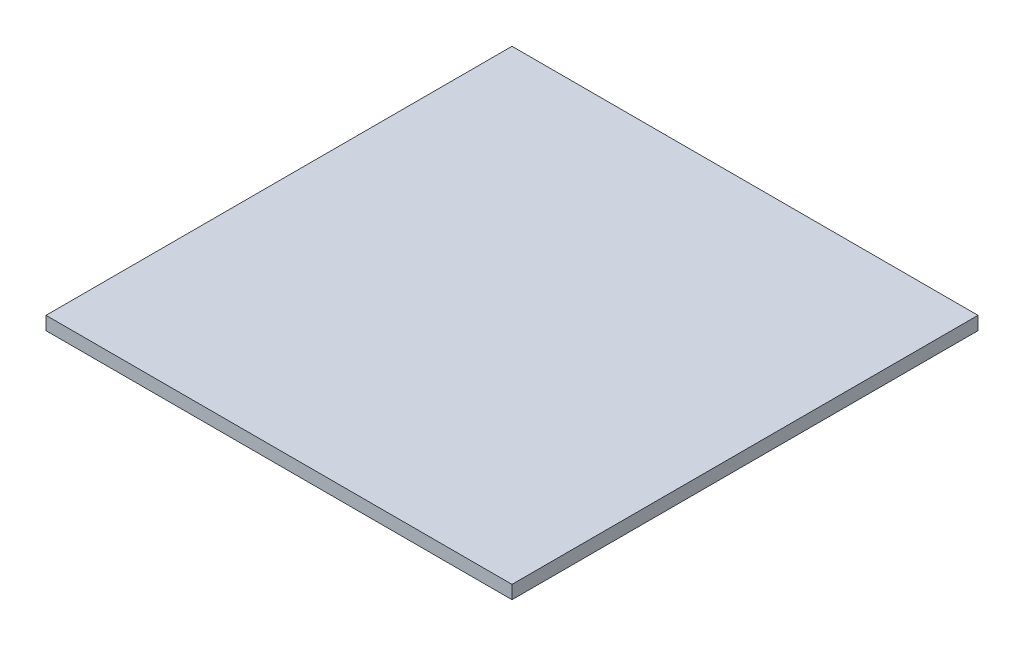
from build123d import *

# Parameters (mm, degrees)
ESQUISSE1_W      = 350
ESQUISSE1_H      = 350
EXTRUSION1_DEPTH = 10


with BuildPart() as part:
    # Esquisse1 → Extrusion1 (new body)
    with BuildSketch(Plane(origin=(0, 0, 0), x_dir=(1, 0, 0), z_dir=(0, 1, 0))):
        with Locations((175, 175)):
            Rectangle(ESQUISSE1_W, ESQUISSE1_H)
    extrude(amount=EXTRUSION1_DEPTH)


solid = part.part
